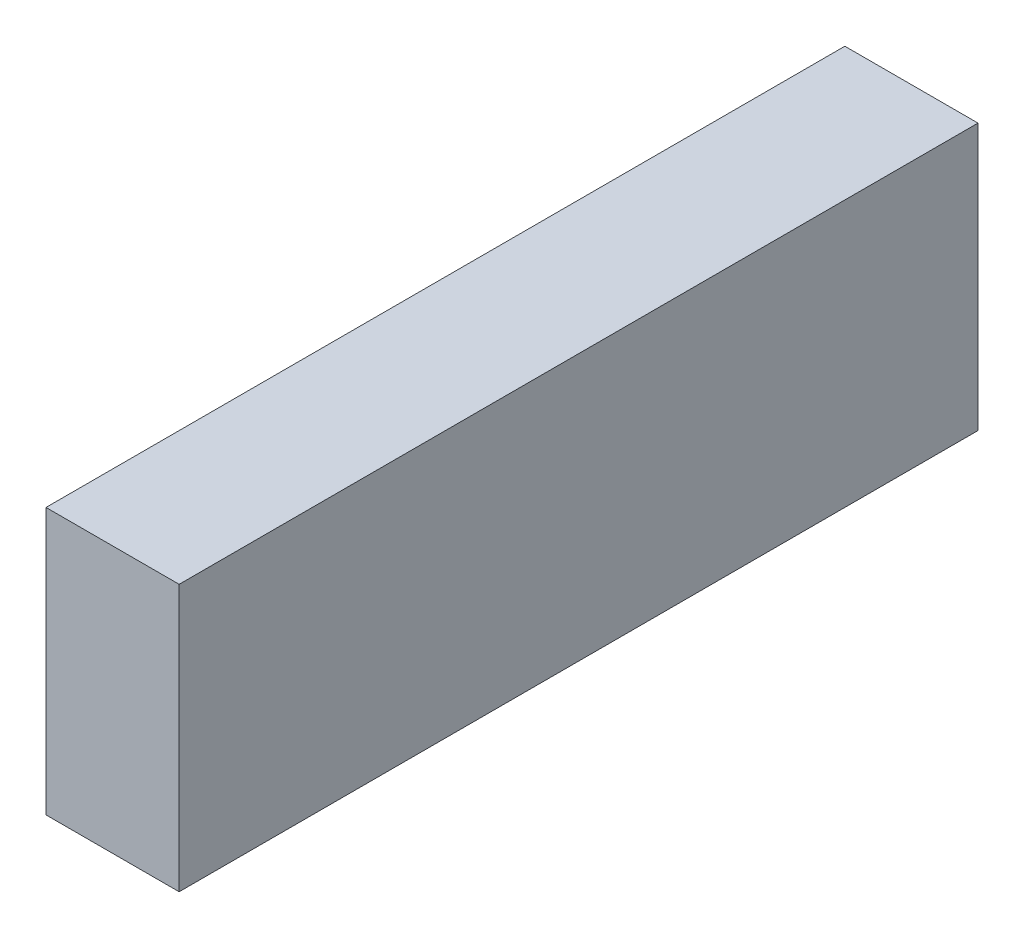
from build123d import *

# Parameters (mm, degrees)
BOSS_EXTRUDE1_DEPTH = 69
SKETCH4_W           = 15
SKETCH4_H           = 124.7
BOSS_EXTRUDE2_DEPTH = 61.9
BOSS_EXTRUDE3_DEPTH = 20.4
FILLET1_R           = 10
SKETCH6_W           = 6000
SKETCH6_H           = 2000
BOSS_EXTRUDE4_DEPTH = 1000
SKETCH8_W           = 880
SKETCH8_H           = 440
BOSS_EXTRUDE5_DEPTH = 220


with BuildPart() as part:
    # Sketch2 → Boss-Extrude1 (new body, symmetric)
    with BuildSketch(Plane(origin=(0, 0, 0), x_dir=(0, 0, -1), z_dir=(1, 0, 0))):
        with BuildLine():
            Line((-262.793626597, 0), (0, 0))
            Line((0, 0), (139.7, 0))
            Line((139.7, 0), (139.7, 81.9))
            Line((139.7, 81.9), (124.7, 81.9))
            Line((124.7, 81.9), (124.7, 20))
            Line((124.7, 20), (0, 20))
            Line((0, 20), (0, 133.7))
            Line((0, 133.7), (-115, 133.7))
            Line((-115, 133.7), (-171.193830238, 94.352656466))
            Line((-171.193830238, 94.352656466), (-262.793626597, 81.479144628))
            Line((-262.793626597, 81.479144628), (-262.793626597, 31.479144628))
            ThreePointArc((-262.793626597, 31.479144628), (-272.644060375, 15.739572314), (-262.793626597, 0))
        make_face()
    extrude(amount=BOSS_EXTRUDE1_DEPTH, both=True)

    # Sketch4 → Boss-Extrude2 (add)
    with BuildSketch(Plane(origin=(0, 20, 0), x_dir=(1, 0, 0), z_dir=(0, 1, 0))):
        with Locations((61.5, 62.35)):
            Rectangle(SKETCH4_W, SKETCH4_H)
    boss_extrude2 = extrude(amount=BOSS_EXTRUDE2_DEPTH)

    # Mirror1: Boss-Extrude2 across plane
    add(boss_extrude2.mirror(Plane(origin=(0, 0, 0), x_dir=(0, 0, 1), z_dir=(1, 0, 0))))

    # Sketch5 → Boss-Extrude3 (add)
    with BuildSketch(Plane(origin=(69, 0, 0), x_dir=(0, 0, -1), z_dir=(1, 0, 0))):
        with BuildLine():
            Line((-224.944060375, 0), (-160.344060375, 0))
            ThreePointArc((-160.344060375, 0), (-192.644060375, -32.3), (-224.944060375, 0))
        make_face()
        with BuildLine():
            Line((28.055939625, 0), (92.655939625, 0))
            ThreePointArc((92.655939625, 0), (60.355939625, -32.3), (28.055939625, 0))
        make_face()
    boss_extrude3 = extrude(amount=-BOSS_EXTRUDE3_DEPTH)

    # Mirror2: Boss-Extrude3 across plane
    add(boss_extrude3.mirror(Plane(origin=(0, 0, 0), x_dir=(0, 0, 1), z_dir=(1, 0, 0))))

    # Fillet1
    fillet1_edges = [part.edges().sort_by_distance(p)[0] for p in [
        (0, 31.479144628, 262.793626597),
        (0, 81.479144628, 262.793626597),
        (0, 94.352656466, 171.193830238),
        (0, 133.7, 115),
        (0, 133.7, 0),
    ]]
    fillet(fillet1_edges, radius=FILLET1_R)


with BuildPart() as body_2:
    # Sketch6 → Boss-Extrude4 (new body)
    with BuildSketch(Plane(origin=(0, 0, 0), x_dir=(0, 0, -1), z_dir=(1, 0, 0))):
        with Locations((807.355939625, 967.7)):
            Rectangle(SKETCH6_W, SKETCH6_H)
    extrude(amount=BOSS_EXTRUDE4_DEPTH)


with BuildPart() as body_3:
    # Sketch8 → Boss-Extrude5 (new body)
    with BuildSketch(Plane(origin=(0, 0, 0), x_dir=(0, 0, -1), z_dir=(1, 0, 0))):
        with Locations((47.355939625, 187.7)):
            Rectangle(SKETCH8_W, SKETCH8_H)
    extrude(amount=BOSS_EXTRUDE5_DEPTH)


solid = Compound([part.part, body_2.part, body_3.part])
